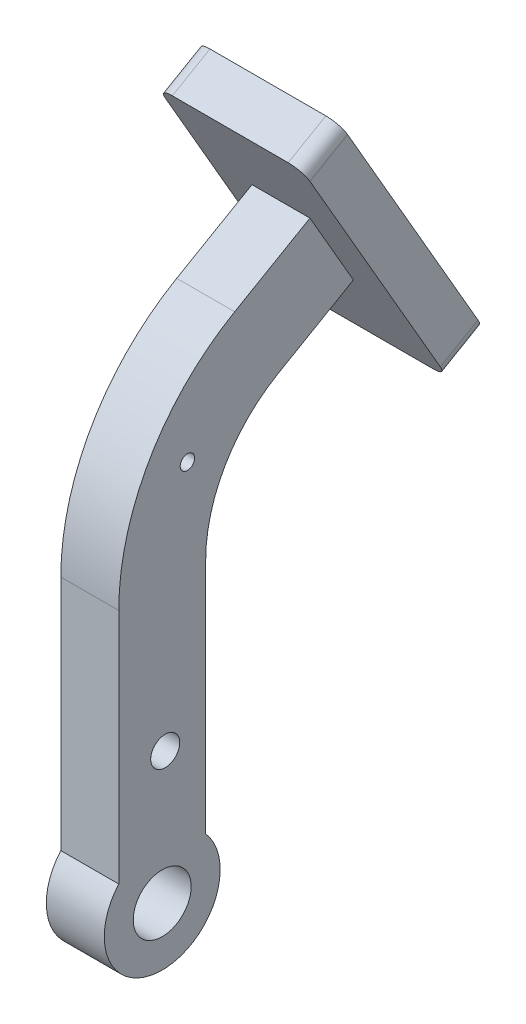
from build123d import *

# Parameters (mm, degrees)
SKETCH3_R           = 10
SKETCH3_R_2         = 5
SKETCH3_R_3         = 2.5
BOSS_EXTRUDE1_DEPTH = 10
BOSS_EXTRUDE2_DEPTH = 25
FILLET1_R           = 5
BOSS_EXTRUDE3_DEPTH = 2
FILLET5_R           = 1


with BuildPart() as part:
    # Sketch3 → Boss-Extrude1 (new, symmetric)
    with BuildSketch(Plane(origin=(0, 0, 0), x_dir=(0, 0, -1), z_dir=(1, 0, 0))):
        with BuildLine():
            Line((65.980762114, 153.301270189), (50.980762114, 179.282032303))
            Line((50.980762114, 179.282032303), (25, 164.282032303))
            ThreePointArc((25, 164.282032303), (-4.282032303, 135), (-15, 95))
            Line((-15, 95), (-15, 13.228756555))
            ThreePointArc((-15, 13.228756555), (0, -20), (15, 13.228756555))
            Line((15, 13.228756555), (15, 95))
            ThreePointArc((15, 95), (21.698729811, 120), (40, 138.301270189))
            Line((40, 138.301270189), (65.980762114, 153.301270189))
        make_face()
        Circle(SKETCH3_R, mode=Mode.SUBTRACT)
        with Locations((1.032464383, 45)):
            Circle(SKETCH3_R_2, mode=Mode.SUBTRACT)
        with Locations((8.708348754, 127.5)):
            Circle(SKETCH3_R_3, mode=Mode.SUBTRACT)
    extrude(amount=BOSS_EXTRUDE1_DEPTH, both=True)

    # Sketch3_3 → Boss-Extrude2 (add, symmetric)
    with BuildSketch(Plane(origin=(0, 0, 0), x_dir=(0, 0, -1), z_dir=(1, 0, 0))):
        Polygon((96.47114317, 130.490381057), (46.47114317, 217.092921435), (33.480762114, 209.592921435), (50.980762114, 179.282032303), (65.980762114, 153.301270189), (83.480762114, 122.990381057), align=None)
    extrude(amount=BOSS_EXTRUDE2_DEPTH, both=True)

    # Fillet1
    fillet1_edges = [part.edges().sort_by_distance(p)[0] for p in [
        (25, 213.342921435, -39.975952642),
        (-25, 213.342921435, -39.975952642),
        (-25, 126.740381057, -89.975952642),
        (25, 126.740381057, -89.975952642),
    ]]
    fillet(fillet1_edges, radius=FILLET1_R)

    # Sketch5 → Boss-Extrude3 (add)
    with BuildSketch(Plane(origin=(0, 74.395825623, -128.85734985), x_dir=(-1, 0, 0), z_dir=(0, 0.4999999999999982, -0.8660254037844396))):
        with BuildLine():
            Line((-10, 149.77241336), (10, 149.77241336))
            ThreePointArc((10, 149.77241336), (15, 144.77241336), (10, 139.77241336))
            Line((10, 139.77241336), (-10, 139.77241336))
            ThreePointArc((-10, 139.77241336), (-15, 144.77241336), (-10, 149.77241336))
        make_face()
        with BuildLine():
            Line((-10, 119.77241336), (10, 119.77241336))
            ThreePointArc((10, 119.77241336), (15, 114.77241336), (10, 109.77241336))
            Line((10, 109.77241336), (-10, 109.77241336))
            ThreePointArc((-10, 109.77241336), (-15, 114.77241336), (-10, 119.77241336))
        make_face()
        with BuildLine():
            Line((-10, 89.77241336), (10, 89.77241336))
            ThreePointArc((10, 89.77241336), (15, 84.77241336), (10, 79.77241336))
            Line((10, 79.77241336), (-10, 79.77241336))
            ThreePointArc((-10, 79.77241336), (-15, 84.77241336), (-10, 89.77241336))
        make_face()
    extrude(amount=BOSS_EXTRUDE3_DEPTH)

    # Fillet5
    fillet5_edges = [part.edges().sort_by_distance(p)[0] for p in [
        (15, 174.791651246, -73.203193978),
        (0, 179.121778265, -70.703193978),
        (-15, 174.791651246, -73.203193978),
        (15, 200.77241336, -58.203193978),
        (0, 205.102540378, -55.703193978),
        (-15, 200.77241336, -58.203193978),
        (0, 153.141016151, -85.703193978),
        (-15, 148.810889132, -88.203193978),
        (0, 144.480762114, -90.703193978),
        (15, 148.810889132, -88.203193978),
        (0, 170.461524227, -75.703193978),
        (0, 196.442286341, -60.703193978),
    ]]
    fillet(fillet5_edges, radius=FILLET5_R)


solid = part.part
